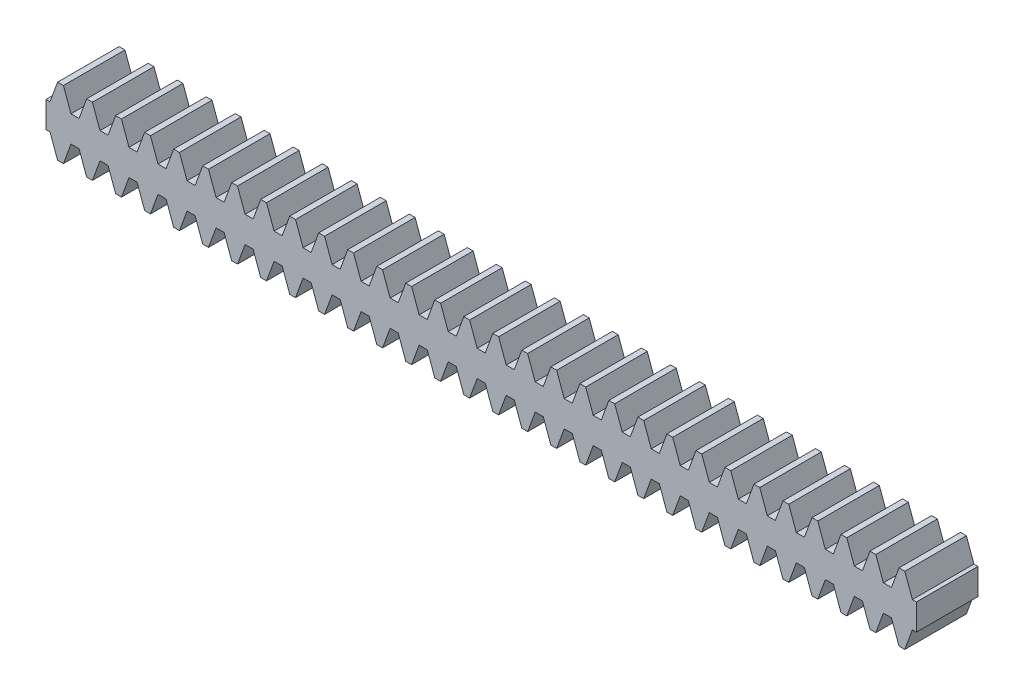
from build123d import *

# Parameters (mm, degrees)
BLANKSKE_W         = 200
BLANKSKE_H         = 5.5
BLANK_DEPTH        = 10
TOOTHCUTSIM_DEPTH  = 201.325360352
TEETHCUTS_COUNT    = 43
TEETHCUTS_PITCH    = 4.712388975
SKETCH2_W          = 63.325143258
SKETCH2_H          = 27.563884476
CUT_EXTRUDE1_DEPTH = 10


with BuildPart() as part:
    # BlankSke → Blank (new body)
    with BuildSketch(Plane.XY):
        with Locations((100, 2.75)):
            Rectangle(BLANKSKE_W, BLANKSKE_H)
    extrude(amount=-BLANK_DEPTH)

    # TooCutSkeSim → ToothCutSim (cut, through all)
    with BuildSketch(Plane.XY):
        Polygon((0.654653055, 2.125), (-0.654653055, 2.125), (-1.892297439, 5.5254), (1.892297439, 5.5254), align=None)
    toothcutsim = extrude(amount=-TOOTHCUTSIM_DEPTH, mode=Mode.SUBTRACT)

    # TeethCuts: ToothCutSim ×43
    with Locations(*[(i * TEETHCUTS_PITCH, 0, 0) for i in range(1, TEETHCUTS_COUNT)]):
        add(toothcutsim, mode=Mode.SUBTRACT)

    # Mirror1: part across plane


with BuildPart() as part_1:
    add(part.part)
    add(part.part.mirror(Plane(origin=(0, 0, -10), x_dir=(0, 0, 1), z_dir=(0, -1, 0))))

    # Sketch2 → Cut-Extrude1 (cut)
    with BuildSketch(Plane.XY):
        with Locations((173.036724083, 3.260735706)):
            Rectangle(SKETCH2_W, SKETCH2_H)
    extrude(amount=-CUT_EXTRUDE1_DEPTH, mode=Mode.SUBTRACT)


solid = part_1.part
